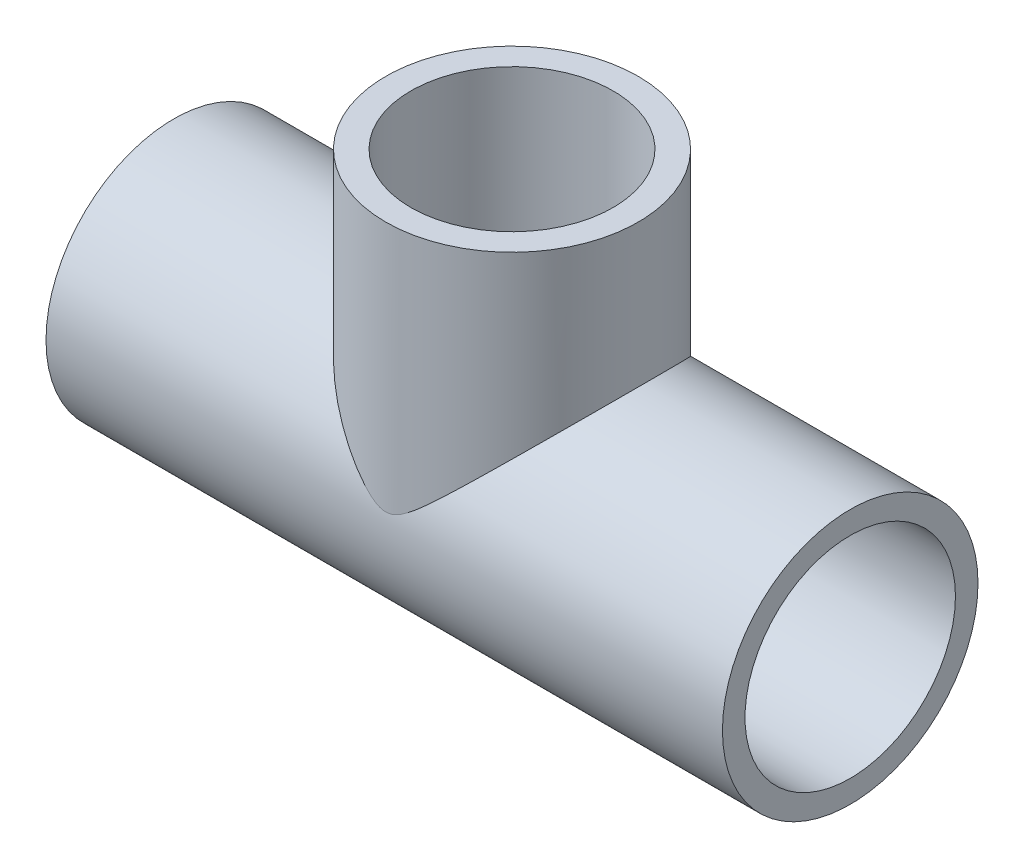
from build123d import *

# Parameters (mm, degrees)
SKETCH2_R           = 13.49375
SKETCH2_R_2         = 11.1125
BOSS_EXTRUDE1_DEPTH = 35.71875
SKETCH5_R           = 13.335
BOSS_EXTRUDE2_DEPTH = 30.32
CUT_EXTRUDE1_REACH  = 44.069
SKETCH6_R           = 10.6807


with BuildPart() as part:
    # Sketch2 → Boss-Extrude1 (new body, symmetric)
    with BuildSketch(Plane(origin=(0, 0, 0), x_dir=(0, 0, -1), z_dir=(1, 0, 0))):
        Circle(SKETCH2_R)
        Circle(SKETCH2_R_2, mode=Mode.SUBTRACT)
    extrude(amount=BOSS_EXTRUDE1_DEPTH, both=True)

    # Sketch5 → Boss-Extrude2 (add)
    with BuildSketch(Plane(origin=(0, 28.575, 0), x_dir=(1, 0, 0), z_dir=(0, 1, 0))):
        Circle(SKETCH5_R)
    extrude(amount=-BOSS_EXTRUDE2_DEPTH)

    # Sketch6 → Cut-Extrude1 (cut, up to next)
    with BuildSketch(Plane(origin=(0, 28.575, 0), x_dir=(1, 0, 0), z_dir=(0, 1, 0)), mode=Mode.PRIVATE) as cut_extrude1_sk1:
        Circle(SKETCH6_R)
    cut_extrude1_tool1 = extrude(cut_extrude1_sk1.sketch, amount=-CUT_EXTRUDE1_REACH, mode=Mode.PRIVATE) & part.part
    add(cut_extrude1_tool1.solids().sort_by_distance((0, 28.575, 0))[0], mode=Mode.SUBTRACT)


solid = part.part
